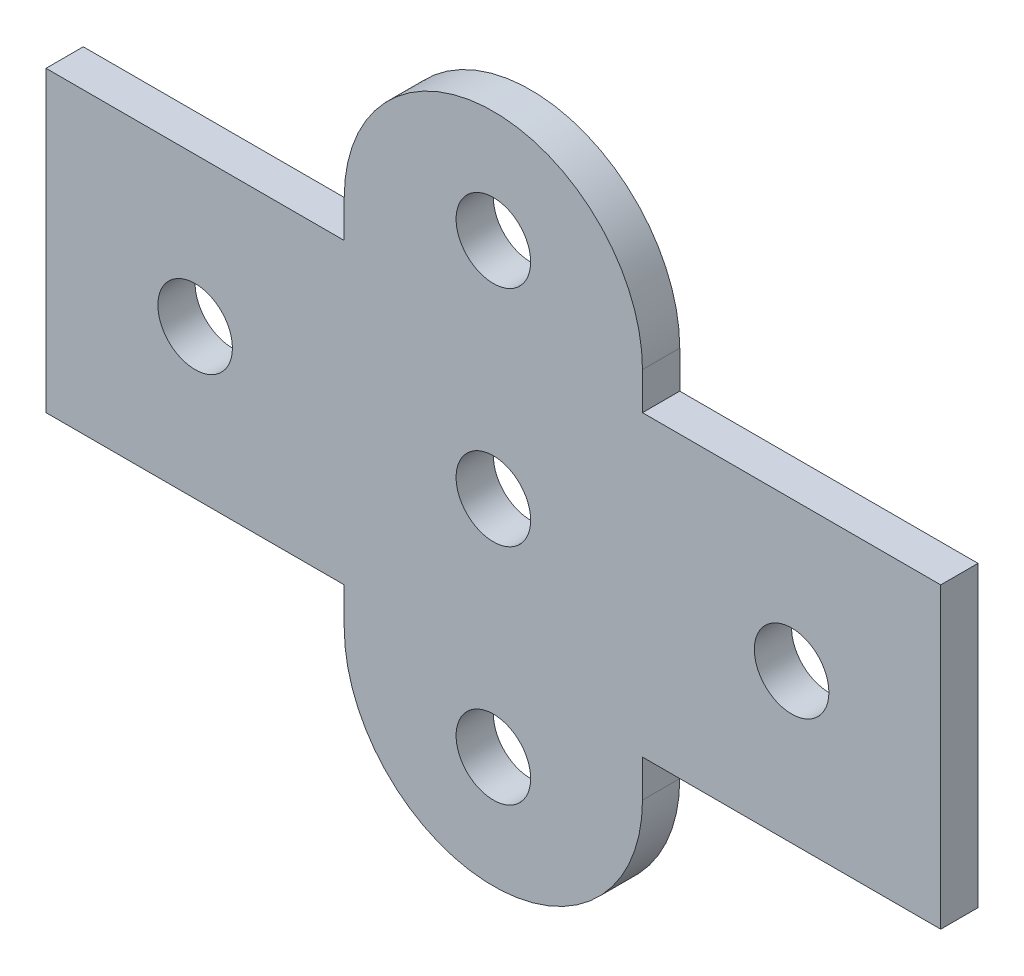
from build123d import *

# Parameters (mm, degrees)
SKETCH1_R           = 3.175
BOSS_EXTRUDE1_DEPTH = 3.175


with BuildPart() as part:
    # Sketch1 → Boss-Extrude1 (new body)
    with BuildSketch(Plane.XY):
        with BuildLine():
            Line((0, 38.1), (-25.4, 38.1))
            Line((-25.4, 38.1), (-25.4, 12.7))
            Line((-25.4, 12.7), (0, 12.7))
            Line((0, 12.7), (0, 9.525))
            ThreePointArc((0, 9.525), (12.7, -3.175), (25.4, 9.525))
            Line((25.4, 9.525), (25.4, 12.7))
            Line((25.4, 12.7), (50.8, 12.7))
            Line((50.8, 12.7), (50.8, 38.1))
            Line((50.8, 38.1), (25.4, 38.1))
            Line((25.4, 38.1), (25.4, 41.275))
            ThreePointArc((25.4, 41.275), (12.7, 53.975), (0, 41.275))
            Line((0, 41.275), (0, 38.1))
        make_face()
        with Locations((12.7, 44.45)):
            Circle(SKETCH1_R, mode=Mode.SUBTRACT)
        with Locations((12.7, 6.35)):
            Circle(SKETCH1_R, mode=Mode.SUBTRACT)
        with Locations((12.7, 25.4)):
            Circle(SKETCH1_R, mode=Mode.SUBTRACT)
        with Locations((38.1, 25.4)):
            Circle(SKETCH1_R, mode=Mode.SUBTRACT)
        with Locations((-12.7, 25.4)):
            Circle(SKETCH1_R, mode=Mode.SUBTRACT)
    extrude(amount=BOSS_EXTRUDE1_DEPTH)


solid = part.part
